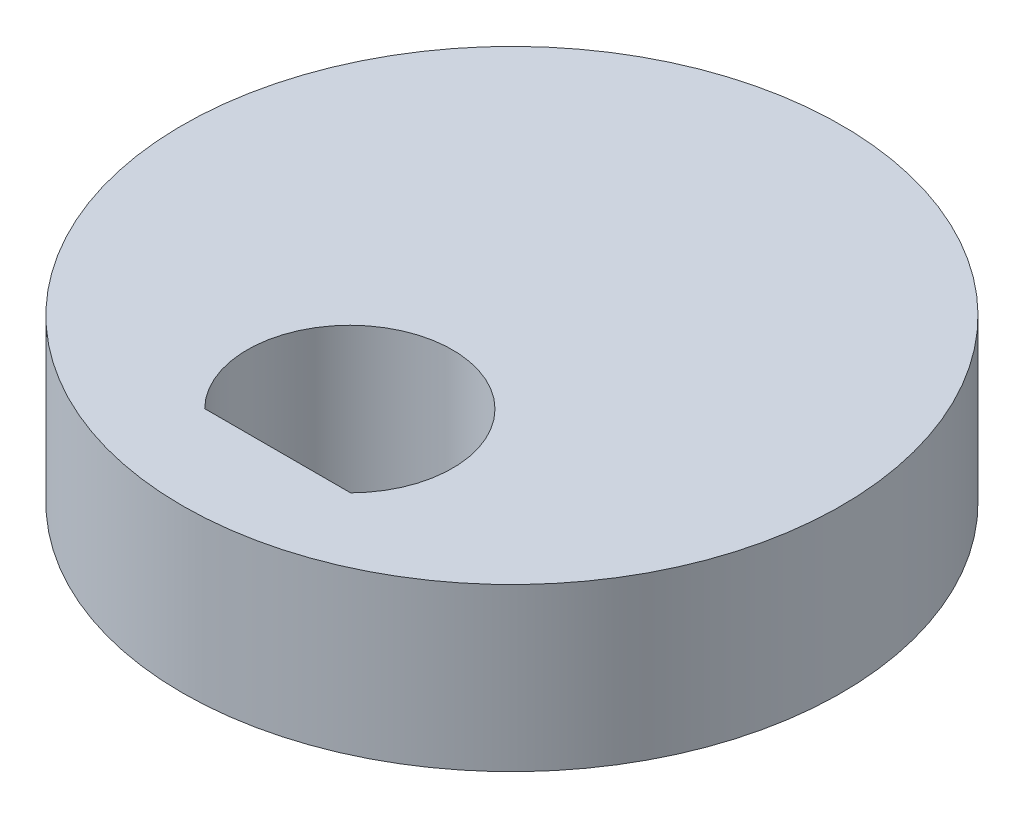
from build123d import *

# Parameters (mm, degrees)
SKETCH1_R           = 6.1
BOSS_EXTRUDE1_DEPTH = 3


with BuildPart() as part:
    # Sketch1 → Boss-Extrude1 (new body)
    with BuildSketch(Plane(origin=(0, 0, 0), x_dir=(1, 0, 0), z_dir=(0, 1, 0))):
        Circle(SKETCH1_R)
        with BuildLine():
            Line((1.35, -4.336974196), (-1.35, -4.336974196))
            ThreePointArc((-1.35, -4.336974196), (0, -1.1), (1.35, -4.336974196))
        make_face(mode=Mode.SUBTRACT)
    extrude(amount=BOSS_EXTRUDE1_DEPTH)


solid = part.part
